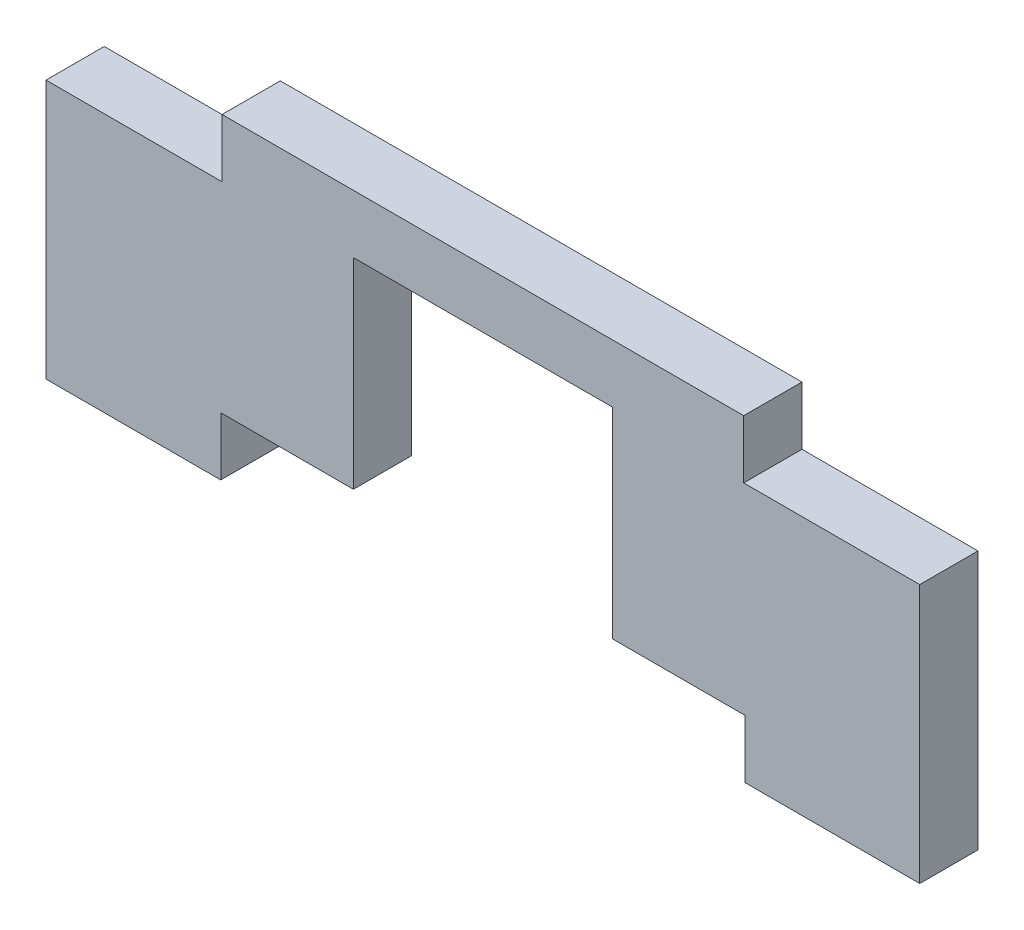
from build123d import *

# Parameters (mm, degrees)
BOSS_EXTRUDE1_DEPTH = 10


with BuildPart() as part:
    # Sketch1 → Boss-Extrude1 (new body)
    with BuildSketch(Plane.XY.offset(232.248004761)):
        Polygon((-82.257473883, 116.914823413), (-82.257473883, 82.464823413), (-82.257473883, 72.464823413), (-52.257473883, 72.464823413), (-52.257473883, 82.464823413), (-29.482473883, 82.464823413), (-29.482473883, 116.914823413), (14.967526117, 116.914823413), (14.967526117, 82.464823413), (37.742526117, 82.464823413), (37.742526117, 72.464823413), (67.742526117, 72.464823413), (67.742526117, 82.464823413), (67.742526117, 116.914823413), (37.52195778, 116.914823413), (37.52195778, 126.914823413), (-52.036905545, 126.914823413), (-52.036905545, 116.914823413), align=None)
    extrude(amount=-BOSS_EXTRUDE1_DEPTH)


solid = part.part
